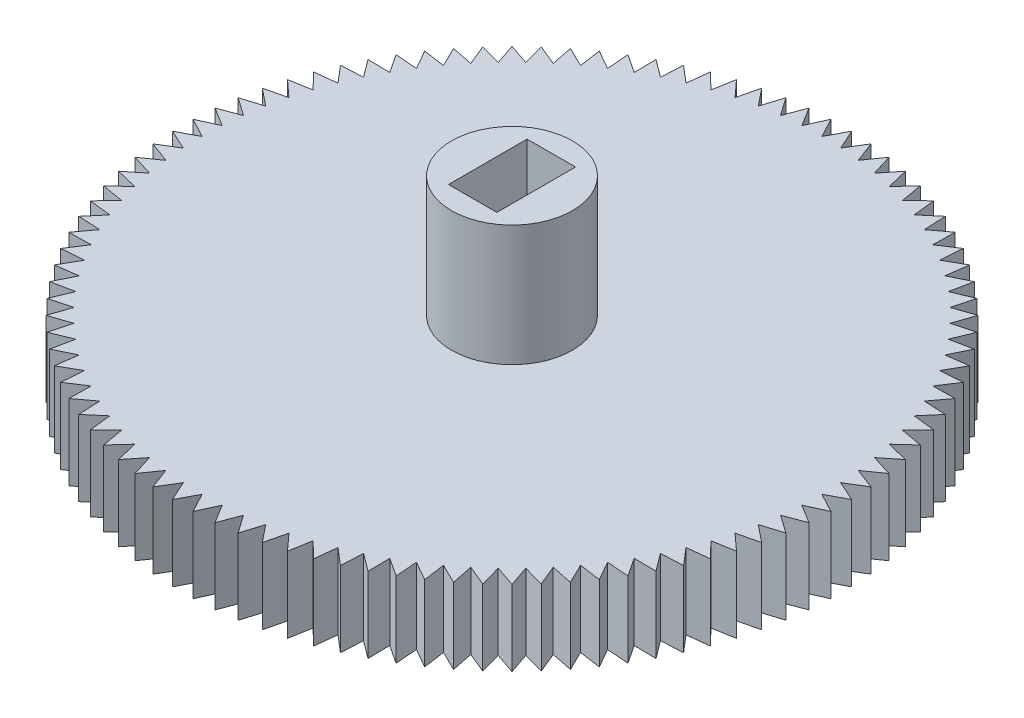
from build123d import *

# Parameters (mm, degrees)
BOSS_EXTRUDE1_DEPTH = 5
SKETCH2_R           = 4
BOSS_EXTRUDE2_DEPTH = 8
SKETCH3_W           = 3.2
SKETCH3_H           = 5.2
CUT_EXTRUDE2_DEPTH  = 14


with BuildPart() as part:
    # Sketch1 → Boss-Extrude1 (new body)
    with BuildSketch(Plane(origin=(0, 0, 0), x_dir=(1, 0, 0), z_dir=(0, 1, 0))):
        Polygon((0, 20.5), (0.684793908, 21.790495485), (1.28720565, 20.459547933), (2.051679156, 21.704498354), (2.569331288, 20.338351377), (3.410467364, 21.532843485), (3.841316949, 20.13688864), (4.755796015, 21.276208319), (5.098142687, 19.855954803), (6.082355712, 20.935605679), (6.334848385, 19.496658584), (7.384911129, 20.512379769), (7.54655333, 19.060417961), (8.658321677, 20.008200866), (8.728475477, 18.548954576), (9.897561784, 19.425058736), (9.875950319, 17.964286941), (11.097740737, 18.765254773), (10.984449297, 17.308722473), (12.254121977, 18.031392923), (12.049597672, 16.584848385), (13.362141796, 17.226369403), (13.06719179, 15.795521477), (14.417427345, 16.353361272), (14.033215672, 14.943856862), (15.415813896, 15.415813896), (14.943856862, 14.033215672), (16.353361272, 14.417427345), (15.795521477, 13.06719179), (17.226369403, 13.362141796), (16.584848385, 12.049597672), (18.031392923, 12.254121977), (17.308722473, 10.984449297), (18.765254773, 11.097740737), (17.964286941, 9.875950319), (19.425058736, 9.897561784), (18.548954576, 8.728475477), (20.008200866, 8.658321677), (19.060417961, 7.54655333), (20.512379769, 7.384911129), (19.496658584, 6.334848385), (20.935605679, 6.082355712), (19.855954803, 5.098142687), (21.276208319, 4.755796015), (20.13688864, 3.841316949), (21.532843485, 3.410467364), (20.338351377, 2.569331288), (21.704498354, 2.051679156), (20.459547933, 1.28720565), (21.790495485, 0.684793908), (20.5, 0), (21.790495485, -0.684793908), (20.459547933, -1.28720565), (21.704498354, -2.051679156), (20.338351377, -2.569331288), (21.532843485, -3.410467364), (20.13688864, -3.841316949), (21.276208319, -4.755796015), (19.855954803, -5.098142687), (20.935605679, -6.082355712), (19.496658584, -6.334848385), (20.512379769, -7.384911129), (19.060417961, -7.54655333), (20.008200866, -8.658321677), (18.548954576, -8.728475477), (19.425058736, -9.897561784), (17.964286941, -9.875950319), (18.765254773, -11.097740737), (17.308722473, -10.984449297), (18.031392923, -12.254121977), (16.584848385, -12.049597672), (17.226369403, -13.362141796), (15.795521477, -13.06719179), (16.353361272, -14.417427345), (14.943856862, -14.033215672), (15.415813896, -15.415813896), (14.033215672, -14.943856862), (14.417427345, -16.353361272), (13.06719179, -15.795521477), (13.362141796, -17.226369403), (12.049597672, -16.584848385), (12.254121977, -18.031392923), (10.984449297, -17.308722473), (11.097740737, -18.765254773), (9.875950319, -17.964286941), (9.897561784, -19.425058736), (8.728475477, -18.548954576), (8.658321677, -20.008200866), (7.54655333, -19.060417961), (7.384911129, -20.512379769), (6.334848385, -19.496658584), (6.082355712, -20.935605679), (5.098142687, -19.855954803), (4.755796015, -21.276208319), (3.841316949, -20.13688864), (3.410467364, -21.532843485), (2.569331288, -20.338351377), (2.051679156, -21.704498354), (1.28720565, -20.459547933), (0.684793908, -21.790495485), (0, -20.5), (-0.684793908, -21.790495485), (-1.28720565, -20.459547933), (-2.051679156, -21.704498354), (-2.569331288, -20.338351377), (-3.410467364, -21.532843485), (-3.841316949, -20.13688864), (-4.755796015, -21.276208319), (-5.098142687, -19.855954803), (-6.082355712, -20.935605679), (-6.334848385, -19.496658584), (-7.384911129, -20.512379769), (-7.54655333, -19.060417961), (-8.658321677, -20.008200866), (-8.728475477, -18.548954576), (-9.897561784, -19.425058736), (-9.875950319, -17.964286941), (-11.097740737, -18.765254773), (-10.984449297, -17.308722473), (-12.254121977, -18.031392923), (-12.049597672, -16.584848385), (-13.362141796, -17.226369403), (-13.06719179, -15.795521477), (-14.417427345, -16.353361272), (-14.033215672, -14.943856862), (-15.415813896, -15.415813896), (-14.943856862, -14.033215672), (-16.353361272, -14.417427345), (-15.795521477, -13.06719179), (-17.226369403, -13.362141796), (-16.584848385, -12.049597672), (-18.031392923, -12.254121977), (-17.308722473, -10.984449297), (-18.765254773, -11.097740737), (-17.964286941, -9.875950319), (-19.425058736, -9.897561784), (-18.548954576, -8.728475477), (-20.008200866, -8.658321677), (-19.060417961, -7.54655333), (-20.512379769, -7.384911129), (-19.496658584, -6.334848385), (-20.935605679, -6.082355712), (-19.855954803, -5.098142687), (-21.276208319, -4.755796015), (-20.13688864, -3.841316949), (-21.532843485, -3.410467364), (-20.338351377, -2.569331288), (-21.704498354, -2.051679156), (-20.459547933, -1.28720565), (-21.790495485, -0.684793908), (-20.5, 0), (-21.790495485, 0.684793908), (-20.459547933, 1.28720565), (-21.704498354, 2.051679156), (-20.338351377, 2.569331288), (-21.532843485, 3.410467364), (-20.13688864, 3.841316949), (-21.276208319, 4.755796015), (-19.855954803, 5.098142687), (-20.935605679, 6.082355712), (-19.496658584, 6.334848385), (-20.512379769, 7.384911129), (-19.060417961, 7.54655333), (-20.008200866, 8.658321677), (-18.548954576, 8.728475477), (-19.425058736, 9.897561784), (-17.964286941, 9.875950319), (-18.765254773, 11.097740737), (-17.308722473, 10.984449297), (-18.031392923, 12.254121977), (-16.584848385, 12.049597672), (-17.226369403, 13.362141796), (-15.795521477, 13.06719179), (-16.353361272, 14.417427345), (-14.943856862, 14.033215672), (-15.415813896, 15.415813896), (-14.033215672, 14.943856862), (-14.417427345, 16.353361272), (-13.06719179, 15.795521477), (-13.362141796, 17.226369403), (-12.049597672, 16.584848385), (-12.254121977, 18.031392923), (-10.984449297, 17.308722473), (-11.097740737, 18.765254773), (-9.875950319, 17.964286941), (-9.897561784, 19.425058736), (-8.728475477, 18.548954576), (-8.658321677, 20.008200866), (-7.54655333, 19.060417961), (-7.384911129, 20.512379769), (-6.334848385, 19.496658584), (-6.082355712, 20.935605679), (-5.098142687, 19.855954803), (-4.755796015, 21.276208319), (-3.841316949, 20.13688864), (-3.410467364, 21.532843485), (-2.569331288, 20.338351377), (-2.051679156, 21.704498354), (-1.28720565, 20.459547933), (-0.684793908, 21.790495485), align=None)
    extrude(amount=BOSS_EXTRUDE1_DEPTH)

    # Sketch2 → Boss-Extrude2 (add)
    with BuildSketch(Plane(origin=(0, 5, 0), x_dir=(1, 0, 0), z_dir=(0, 1, 0))):
        Circle(SKETCH2_R)
    extrude(amount=BOSS_EXTRUDE2_DEPTH)

    # Sketch3 → Cut-Extrude2 (cut, through all)
    with BuildSketch(Plane(origin=(0, 13, 0), x_dir=(1, 0, 0), z_dir=(0, 1, 0))):
        Rectangle(SKETCH3_W, SKETCH3_H)
    extrude(amount=-CUT_EXTRUDE2_DEPTH, mode=Mode.SUBTRACT)


solid = part.part
